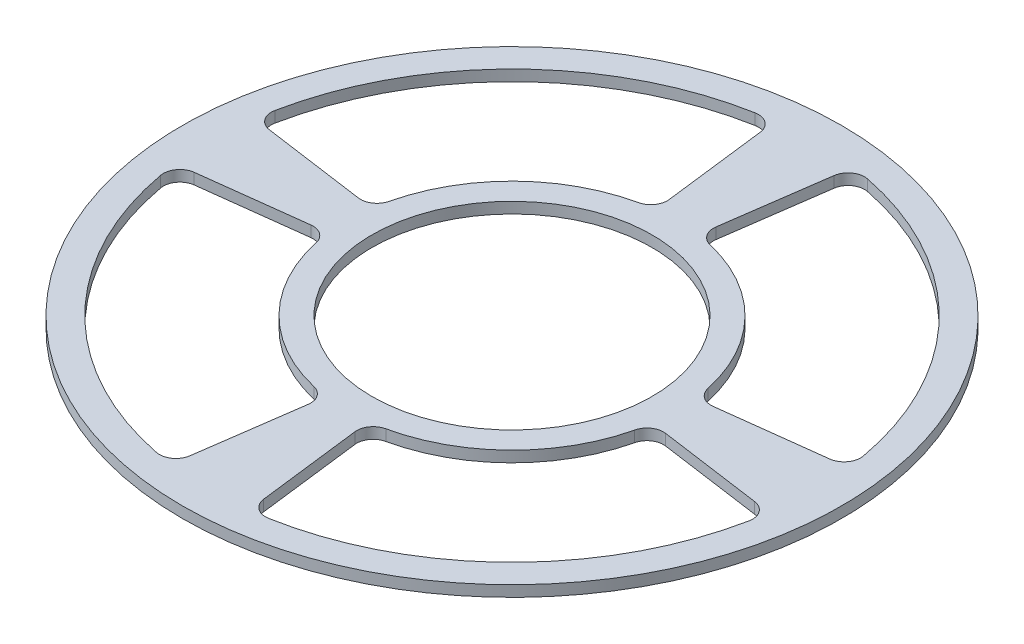
from build123d import *

# Parameters (mm, degrees)
SKETCH1_R           = 60
SKETCH1_R_2         = 25.5
BOSS_EXTRUDE1_DEPTH = 2
CUT_EXTRUDE1_DEPTH  = 2
CIRPATTERN1_COUNT   = 4


with BuildPart() as part:
    # Sketch1 → Boss-Extrude1 (new body)
    with BuildSketch(Plane(origin=(0, 0, 0), x_dir=(1, 0, 0), z_dir=(0, 1, 0))):
        Circle(SKETCH1_R)
        Circle(SKETCH1_R_2, mode=Mode.SUBTRACT)
    extrude(amount=BOSS_EXTRUDE1_DEPTH)

    # Sketch2 → Cut-Extrude1 (cut)
    with BuildSketch(Plane(origin=(0, 2, 0), x_dir=(1, 0, 0), z_dir=(0, 1, 0))):
        with BuildLine():
            Line((-32.618394997, -4.005035307), (-51.526434877, -6.326650681))
            ThreePointArc((-51.526434877, -6.326650681), (-53.577175122, -7.526295601), (-54.112413011, -9.841075048))
            ThreePointArc((-54.112413011, -9.841075048), (-39.228774703, -38.550009536), (-10.78396803, -53.932420987))
            ThreePointArc((-10.78396803, -53.932420987), (-8.460199946, -53.437663089), (-7.224947385, -51.408171873))
            Line((-7.224947385, -51.408171873), (-4.573694808, -32.543529554))
            ThreePointArc((-4.573694808, -32.543529554), (-5.068923242, -30.431452905), (-6.858635467, -29.205463864))
            ThreePointArc((-6.858635467, -29.205463864), (-21.397513475, -21.027277929), (-29.320715424, -6.347885238))
            ThreePointArc((-29.320715424, -6.347885238), (-30.515282955, -4.537049136), (-32.618394997, -4.005035307))
        make_face()
    cut_extrude1 = extrude(amount=-CUT_EXTRUDE1_DEPTH, mode=Mode.SUBTRACT)

    # CirPattern1: Cut-Extrude1 ×4 about axis
    cirpattern1_axis = Axis((0, 0, 0), (0, 1, 0))
    for i in range(1, CIRPATTERN1_COUNT):
        add(cut_extrude1.rotate(cirpattern1_axis, i * 360 / CIRPATTERN1_COUNT), mode=Mode.SUBTRACT)


solid = part.part
